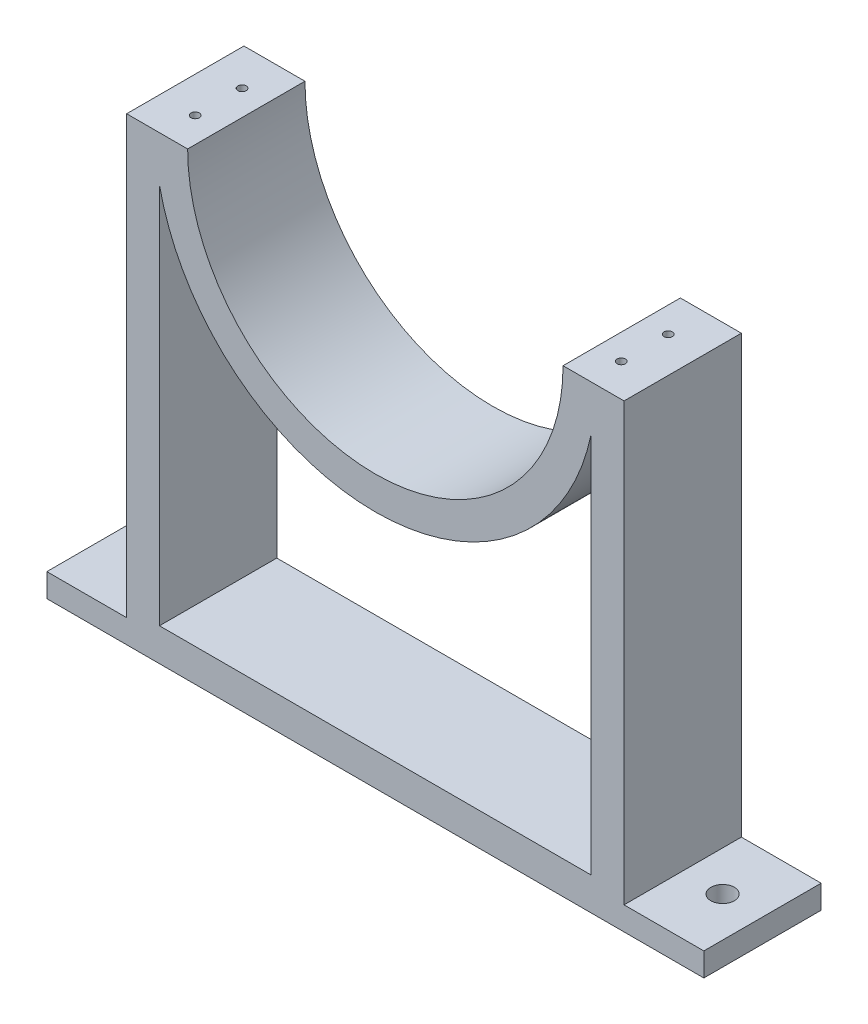
from build123d import *

# Parameters (mm, degrees)
BOSS_EXTRUDE1_DEPTH       = 15.875
SHELL1_T                  = -8.89
SKETCH2_R                 = 3.175
CUT_EXTRUDE1_DEPTH        = 7.35
F_4_40_TAPPED_HOLE1_D     = 2.2606
F_4_40_TAPPED_HOLE1_DEPTH = 7.62
F_4_40_TAPPED_HOLE1_TIP   = 0.679153


with BuildPart() as part:
    # Sketch1 → Boss-Extrude1 (new body, symmetric)
    with BuildSketch(Plane.XY):
        with BuildLine():
            ThreePointArc((0, -50.8), (-35.921024, -35.921024), (-50.8, 0))
            Line((-50.8, 0), (-67.31, 0))
            Line((-67.31, 0), (-67.31, -118.11))
            Line((-67.31, -118.11), (-88.9, -118.11))
            Line((-88.9, -118.11), (-88.9, -124.46))
            Line((-88.9, -124.46), (0, -124.46))
            Line((0, -124.46), (0, -50.8))
        make_face()
        with BuildLine():
            ThreePointArc((50.8, 0), (35.921024, -35.921024), (0, -50.8))
            Line((0, -50.8), (0, -124.46))
            Line((0, -124.46), (88.9, -124.46))
            Line((88.9, -124.46), (88.9, -118.11))
            Line((88.9, -118.11), (67.31, -118.11))
            Line((67.31, -118.11), (67.31, 0))
            Line((67.31, 0), (50.8, 0))
        make_face()
    extrude(amount=BOSS_EXTRUDE1_DEPTH, both=True)

    # Shell1
    shell1_openings = [part.faces().sort_by_distance(p)[0] for p in [
        (0, -77.216, 15.875),
        (0, -77.216, -15.875),
    ]]
    offset(amount=SHELL1_T, openings=shell1_openings)

    # Sketch2 → Cut-Extrude1 (cut, through all)
    with BuildSketch(Plane(origin=(0, -118.11, 0), x_dir=(1, 0, 0), z_dir=(0, 1, 0))):
        with Locations((-78.105, 0)):
            Circle(SKETCH2_R)
        with Locations((78.105, 0)):
            Circle(SKETCH2_R)
    extrude(amount=-CUT_EXTRUDE1_DEPTH, mode=Mode.SUBTRACT)

    # #4-40 Tapped Hole1
    with Locations(Plane(origin=(0, 0, 0), x_dir=(1, 0, 0), z_dir=(0, 1, 0))):
        with Locations((-57.658, 5.715), (-57.658, -6.985), (57.658, -6.985), (57.658, 5.715)):
            Hole(F_4_40_TAPPED_HOLE1_D / 2, depth=F_4_40_TAPPED_HOLE1_DEPTH)
            with Locations((0, 0, -(F_4_40_TAPPED_HOLE1_DEPTH + F_4_40_TAPPED_HOLE1_TIP / 2))):  # 118° drill point
                Cone(0, F_4_40_TAPPED_HOLE1_D / 2, F_4_40_TAPPED_HOLE1_TIP, mode=Mode.SUBTRACT)


solid = part.part
